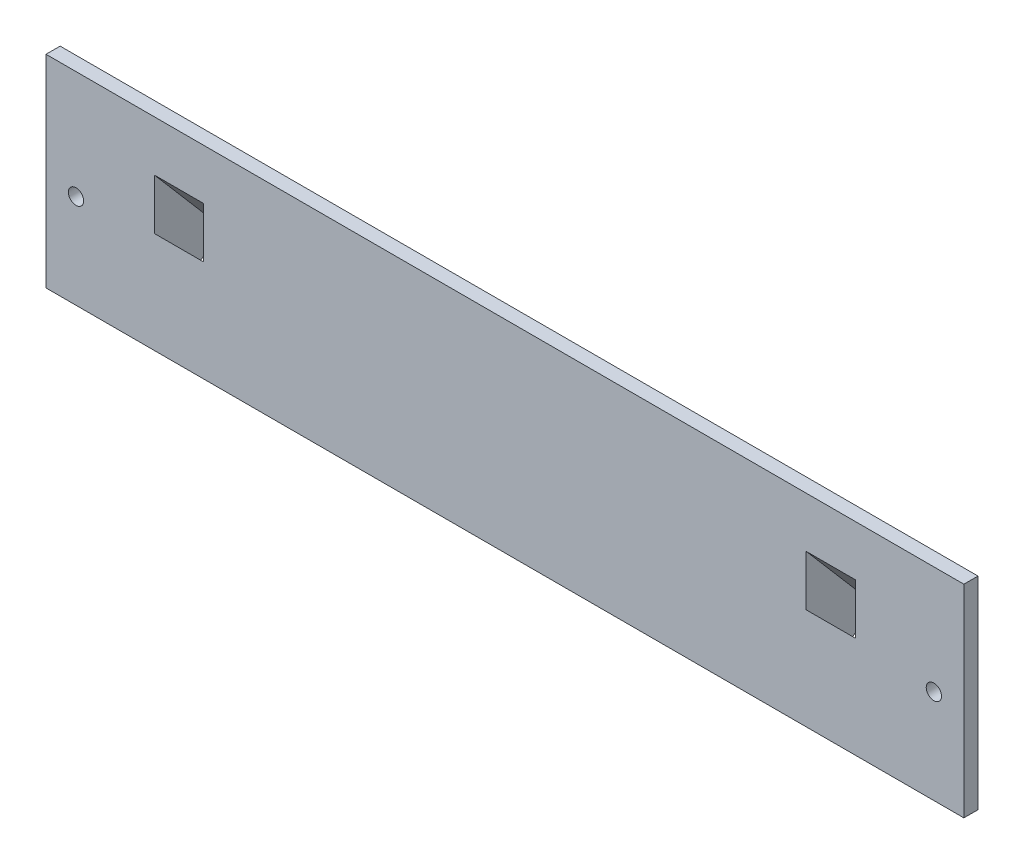
from build123d import *

# Parameters (mm, degrees)
CROQUIS1_W              = 195
CROQUIS1_H              = 38
CROQUIS1_R              = 1.625
SALIENTE_EXTRUIR1_DEPTH = 3
SALIENTE_EXTRUIR2_START = -20
SALIENTE_EXTRUIR2_DEPTH = 16.5
CROQUIS3_W              = 10.5
CROQUIS3_H              = 7
CORTAR_EXTRUIR1_DEPTH   = 31.243984
SALIENTE_EXTRUIR3_START = -20
SALIENTE_EXTRUIR3_DEPTH = 16.5
CROQUIS5_W              = 10.5
CROQUIS5_H              = 7
CORTAR_EXTRUIR2_DEPTH   = 31.243984
SALIENTE_EXTRUIR4_START = -120
SALIENTE_EXTRUIR4_DEPTH = 45
CROQUIS7_R              = 8.25
CORTAR_EXTRUIR3_DEPTH   = 31.243984
CROQUIS8_W              = 195
CROQUIS8_H              = 3
SALIENTE_EXTRUIR5_DEPTH = 5
CORTAR_EXTRUIR4_REACH   = 122
CROQUIS10_W             = 55.675323807
CROQUIS10_H             = 32.604384831
SALIENTE_EXTRUIR7_DEPTH = 3


with BuildPart() as part:
    # Croquis1 → Saliente-Extruir1 (new body)
    with BuildSketch(Plane.XY):
        with Locations((0, 19)):
            Rectangle(CROQUIS1_W, CROQUIS1_H)
        with Locations((91.125, 15)):
            Circle(CROQUIS1_R, mode=Mode.SUBTRACT)
        with Locations((-91.125, 15)):
            Circle(CROQUIS1_R, mode=Mode.SUBTRACT)
    extrude(amount=SALIENTE_EXTRUIR1_DEPTH)

    # Croquis2 → Saliente-Extruir2 (add)
    with BuildSketch(Plane(origin=(97.5, 0, 0), x_dir=(0, 0, -1), z_dir=(1, 0, 0)).offset(SALIENTE_EXTRUIR2_START)):
        Polygon((3.429565646, 3.677896428), (15.185426147, 13.753887502), (0, 31.471028189), (0, 0.738403157), align=None)
    extrude(amount=-SALIENTE_EXTRUIR2_DEPTH)

    # Croquis3 → Cortar-Extruir1 (cut, through all)
    with BuildSketch(Plane(origin=(0, 0.425684191, 0.364855478), x_dir=(1, 0, 0), z_dir=(0, -0.759271307, -0.650774217))):
        with Locations((69.25, -11.980533736)):
            Rectangle(CROQUIS3_W, CROQUIS3_H)
    extrude(amount=-CORTAR_EXTRUIR1_DEPTH, mode=Mode.SUBTRACT)

    # Croquis4 → Saliente-Extruir3 (add)
    with BuildSketch(Plane.ZY.offset(97.5).offset(SALIENTE_EXTRUIR3_START)):
        Polygon((0, 0.738403157), (-15.185426147, 13.753887502), (0, 31.471028189), align=None)
    extrude(amount=-SALIENTE_EXTRUIR3_DEPTH)

    # Croquis5 → Cortar-Extruir2 (cut, through all)
    with BuildSketch(Plane(origin=(0, 0.425684191, 0.364855478), x_dir=(1, 0, 0), z_dir=(0, -0.759271307, -0.650774217))):
        with Locations((-69.25, -11.980533736)):
            Rectangle(CROQUIS5_W, CROQUIS5_H)
    extrude(amount=-CORTAR_EXTRUIR2_DEPTH, mode=Mode.SUBTRACT)

    # Croquis6 → Saliente-Extruir4 (add)
    with BuildSketch(Plane(origin=(97.5, 0, 0), x_dir=(0, 0, -1), z_dir=(1, 0, 0)).offset(SALIENTE_EXTRUIR4_START)):
        Polygon((0, 0.738403157), (15.185426147, 13.753887502), (0, 31.471028189), align=None)
    extrude(amount=SALIENTE_EXTRUIR4_DEPTH)

    # Croquis7 → Cortar-Extruir3 (cut, through all)
    with BuildSketch(Plane(origin=(0, 0.425684191, 0.364855478), x_dir=(1, 0, 0), z_dir=(0, -0.759271307, -0.650774217))):
        with Locations((-12.92, -10.480533736)):
            Circle(CROQUIS7_R)
        with Locations((12.93, -10.480533736)):
            Circle(CROQUIS7_R)
    extrude(amount=-CORTAR_EXTRUIR3_DEPTH, mode=Mode.SUBTRACT)

    # Croquis8 → Saliente-Extruir5 (add)
    with BuildSketch(Plane.XZ):
        with Locations((0, 1.5)):
            Rectangle(CROQUIS8_W, CROQUIS8_H)
    extrude(amount=SALIENTE_EXTRUIR5_DEPTH)

    # Croquis9 → Cortar-Extruir4 (cut, up to next)
    with BuildSketch(Plane.ZY.offset(22.5), mode=Mode.PRIVATE) as cortar_extruir4_sk1:
        Polygon((0, 0.738403157), (-15.185426147, 13.753887502), (0, 31.471028189), align=None)
    cortar_extruir4_tool1 = extrude(cortar_extruir4_sk1.sketch, amount=-CORTAR_EXTRUIR4_REACH, mode=Mode.PRIVATE) & part.part
    add(cortar_extruir4_tool1.solids().sort_by_distance((-22.5, 15.321106, -5.061809))[0], mode=Mode.SUBTRACT)

    # Croquis10 → Saliente-Extruir7 (add)
    with BuildSketch(Plane.XY.offset(3)):
        with Locations((-1.24159067, 18.458583135)):
            Rectangle(CROQUIS10_W, CROQUIS10_H)
    extrude(amount=-SALIENTE_EXTRUIR7_DEPTH)


solid = part.part
